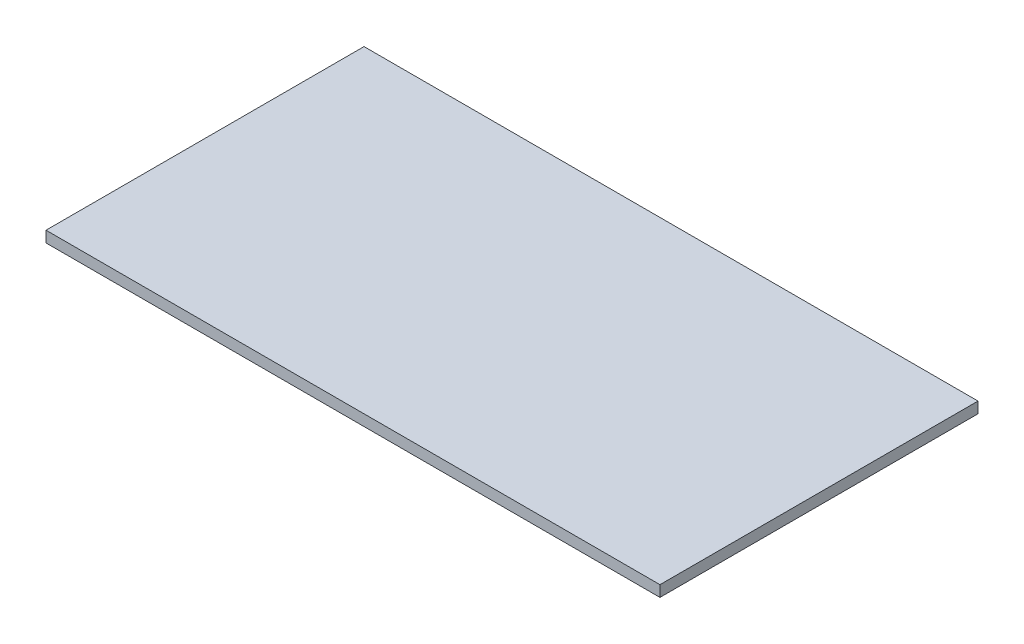
from build123d import *

# Parameters (mm, degrees)
SKETCH_1_W      = 100
SKETCH_1_H      = 51.8
EXTRUDE_1_DEPTH = 1.8


with BuildPart() as part:
    # 草图1 → 凸台-拉伸1 (new body)
    with BuildSketch(Plane(origin=(0, 0, 0), x_dir=(1, 0, 0), z_dir=(0, 1, 0))):
        with Locations((50, 25.9)):
            Rectangle(SKETCH_1_W, SKETCH_1_H)
    extrude(amount=EXTRUDE_1_DEPTH)


solid = part.part
